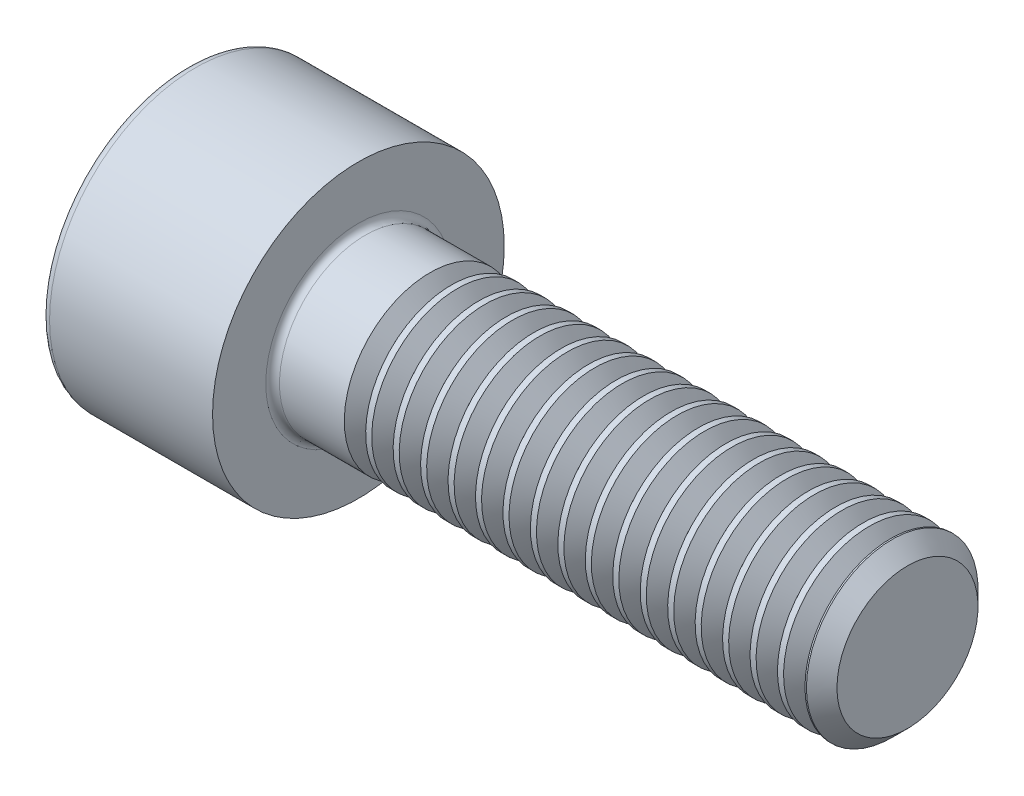
from build123d import *

# Parameters (mm, degrees)
FILLET1_R       = 0.2
FILLET2_R       = 0.25
HEX_2_DEPTH     = 2.5
THDSCHPAT_COUNT = 17
THDSCHPAT_PITCH = 0.8


with BuildPart() as part:
    # BodySke → Base-Revolve (revolve)
    with BuildSketch(Plane.XY):
        Polygon((0, 0), (0, 4.25), (5, 4.25), (5, 2.5), (20.555, 2.5), (21, 2.055), (21, 0), align=None)
    revolve(axis=Axis((-31.75, 0, 0), (1, 0, 0)))

    # Fillet1
    fillet1_edges = [part.edges().sort_by_distance(p)[0] for p in [
        (5, -2.5, 0),
    ]]
    fillet(fillet1_edges, radius=FILLET1_R)

    # Fillet2
    fillet2_edges = [part.edges().sort_by_distance(p)[0] for p in [
        (0, -4.25, 0),
    ]]
    fillet(fillet2_edges, radius=FILLET2_R)

    # Sketch2 → Hex-PreBroach (revolve, cut)
    with BuildSketch(Plane.XY):
        Polygon((0, 2.042), (2.5, 2.042), (3.67894925, 0), (0, 0), align=None)
    revolve(axis=Axis((0, 0, 0), (1, 0, 0)), mode=Mode.SUBTRACT)

    # Sketch3 → Hex 2 (cut)
    with BuildSketch(Plane(origin=(0, 0, 0), x_dir=(0, 0.5, 0.866025404), z_dir=(-1, 0, 0))):
        Polygon((1.17894925, 2.042), (-1.17894925, 2.042), (-2.357898499, 0), (-1.17894925, -2.042), (1.17894925, -2.042), (2.357898499, 0), align=None)
    extrude(amount=-HEX_2_DEPTH, mode=Mode.SUBTRACT)

    # ThdSchSke → ThreadSchematic (revolve, cut)
    with BuildSketch(Plane.XY):
        Polygon((7.4, -2.055), (7.088407645, -2.5), (7.088407645, -3.125), (7.711592355, -3.125), (7.711592355, -2.5), align=None)
    threadschematic = revolve(axis=Axis((-3.175, 0, 0), (1, 0, 0)), mode=Mode.SUBTRACT)

    # ThdSchPat: ThreadSchematic ×17
    with Locations(*[(i * THDSCHPAT_PITCH, 0, 0) for i in range(1, THDSCHPAT_COUNT)]):
        add(threadschematic, mode=Mode.SUBTRACT)


solid = part.part
